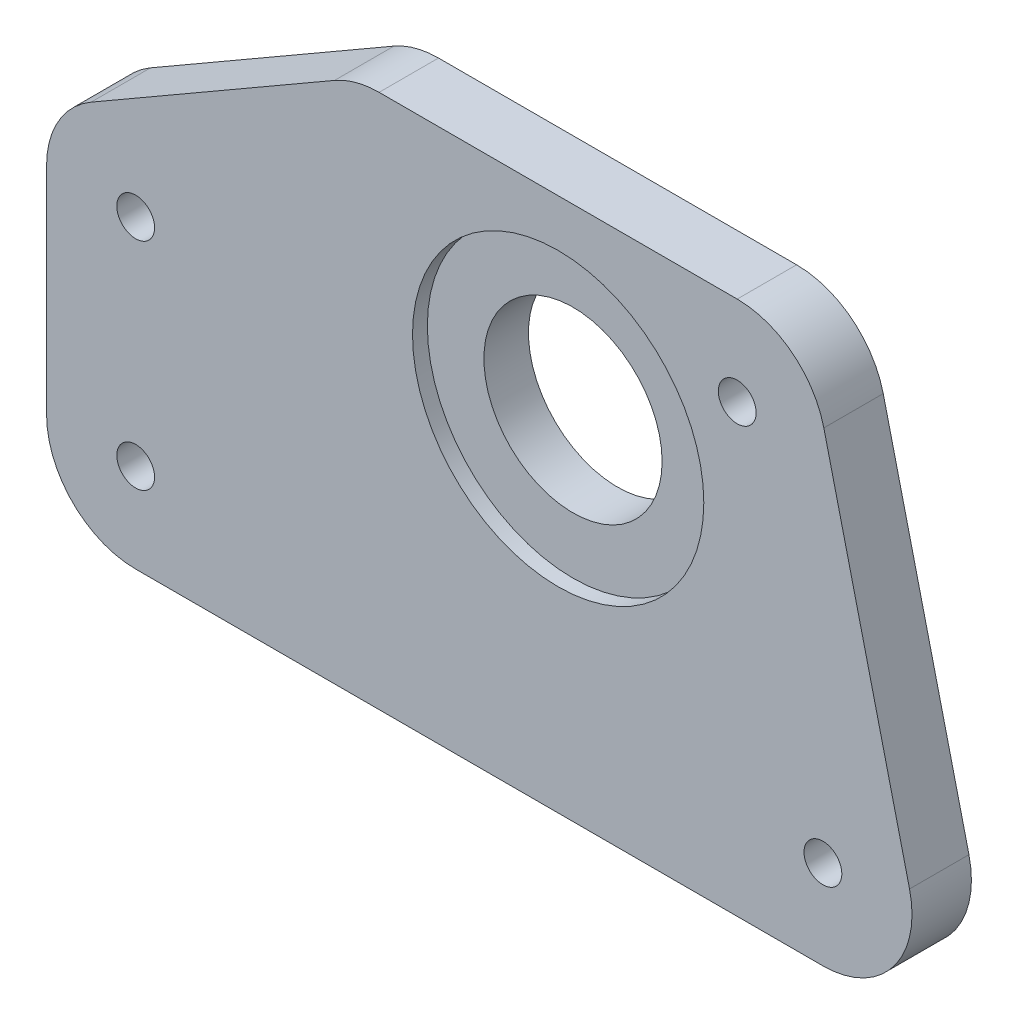
from build123d import *

# Parameters (mm, degrees)
SKETCH1_R                  = 9.525
BOSS_EXTRUDE1_DEPTH        = 6.35
SKETCH6_R                  = 15.5702
CUT_EXTRUDE2_DEPTH         = 1.5875
TAP_DRILL_FOR_10_32_TAP1_D = 4.0386


with BuildPart() as part:
    # Sketch1 → Boss-Extrude1 (new body)
    with BuildSketch(Plane.XY):
        with BuildLine():
            Line((-45.162617117, -36.5125), (28.303378868, -36.5125))
            ThreePointArc((28.303378868, -36.5125), (35.784732944, -32.882834273), (37.564288704, -24.760130697))
            Line((37.564288704, -24.760130697), (28.400743011, 13.339869303))
            ThreePointArc((28.400743011, 13.339869303), (25.035167449, 18.593854076), (19.139833175, 20.6375))
            Line((19.139833175, 20.6375), (-19.139833175, 20.6375))
            ThreePointArc((-19.139833175, 20.6375), (-21.60508458, 20.312943495), (-23.902333175, 19.361391971))
            Line((-23.902333175, 19.361391971), (-49.925117117, 4.337130657))
            ThreePointArc((-49.925117117, 4.337130657), (-53.411509088, 0.850738686), (-54.687617117, -3.911761314))
            Line((-54.687617117, -3.911761314), (-54.687617117, -26.9875))
            ThreePointArc((-54.687617117, -26.9875), (-51.897809208, -33.722692091), (-45.162617117, -36.5125))
        make_face()
        Circle(SKETCH1_R, mode=Mode.SUBTRACT)
    extrude(amount=BOSS_EXTRUDE1_DEPTH)

    # Sketch6 → Cut-Extrude2 (cut)
    with BuildSketch(Plane.XY.offset(6.35)):
        Circle(SKETCH6_R)
    extrude(amount=-CUT_EXTRUDE2_DEPTH, mode=Mode.SUBTRACT)

    # Tap Drill for #10-32 Tap1 (through all)
    with Locations(Plane(origin=(0, 0, 0), x_dir=(-1, 0, 0), z_dir=(0, 0, -1))):
        with Locations((-28.303378868, -26.9875), (-19.139833175, 11.1125), (45.162617117, -3.911761314), (45.162617117, -26.9875)):
            Hole(TAP_DRILL_FOR_10_32_TAP1_D / 2)


solid = part.part
